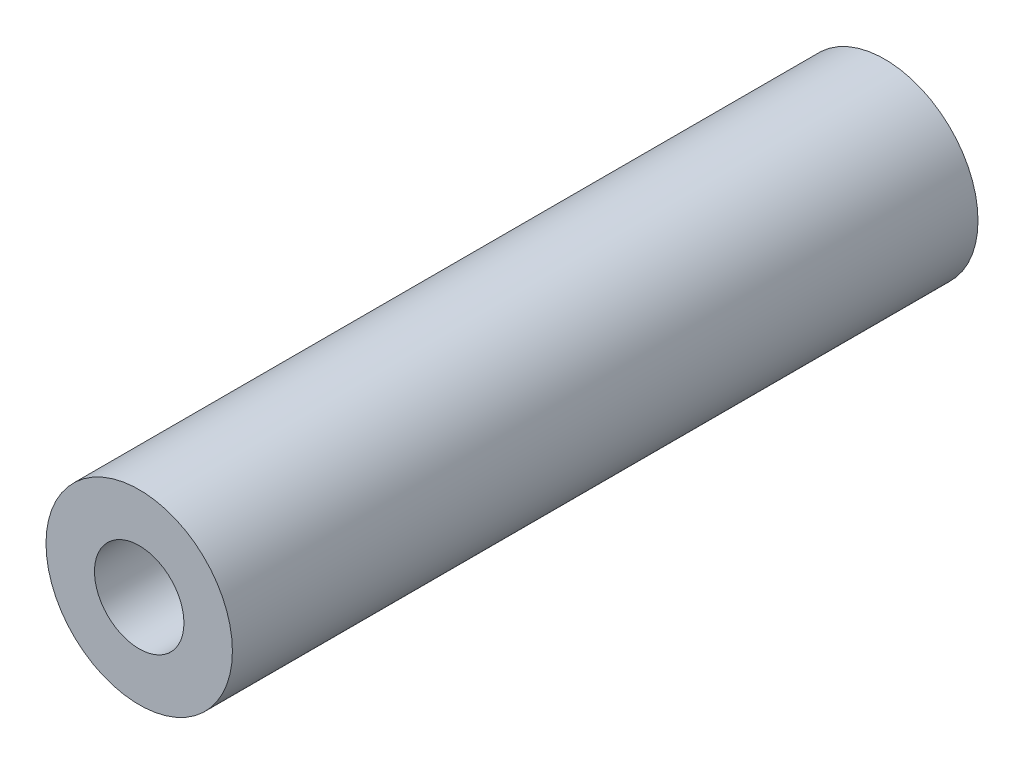
from build123d import *

# Parameters (mm, degrees)
SKETCH1_R      = 3.175
SKETCH1_R_2    = 1.524
EXTRUDE1_DEPTH = 25.4


with BuildPart() as part:
    # Sketch1 → Extrude1 (new body)
    with BuildSketch(Plane.XY):
        Circle(SKETCH1_R)
        Circle(SKETCH1_R_2, mode=Mode.SUBTRACT)
    extrude(amount=EXTRUDE1_DEPTH)


solid = part.part
